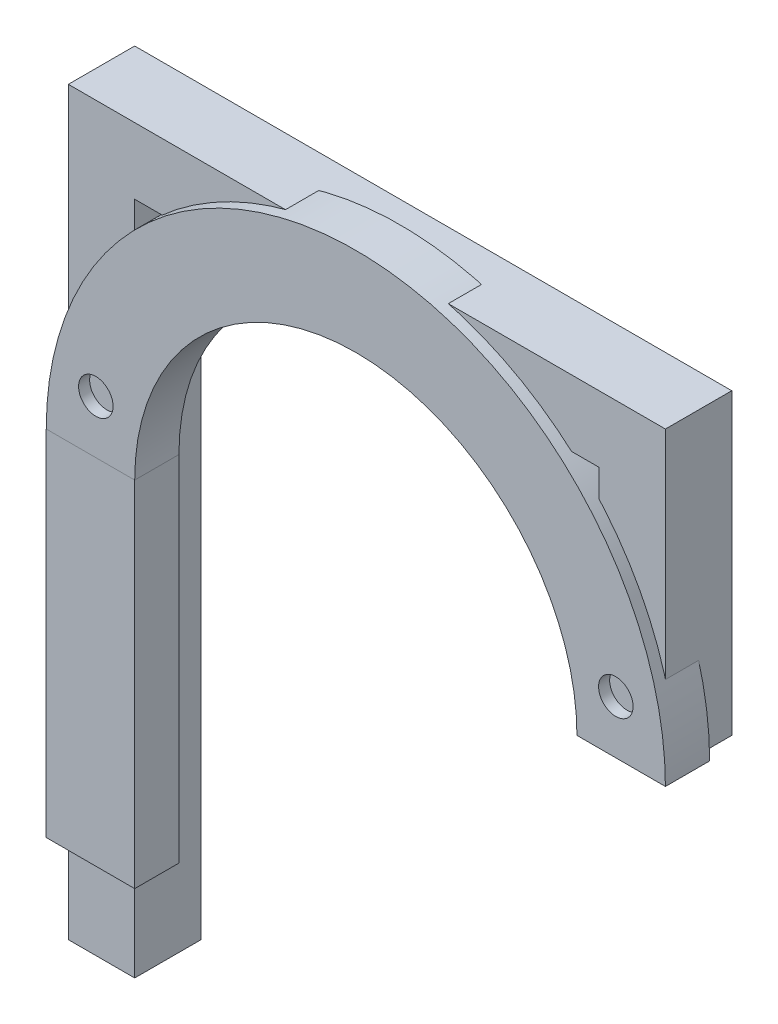
from build123d import *

# Parameters (mm, degrees)
EXTRUDE_THIN3_DEPTH = 4.7625
SKETCH38_W          = 12.7
SKETCH38_H          = 6.35
SKETCH39_R          = 2.4765
CUT_EXTRUDE1_DEPTH  = 7.35
SKETCH42_W          = 12.7
SKETCH42_H          = 6.35
CUT_EXTRUDE2_DEPTH  = 12.7
SKETCH43_W          = 9.525
SKETCH43_H          = 4.7625
BOSS_EXTRUDE4_DEPTH = 12.7
SKETCH45_R          = 2.4765
CUT_EXTRUDE4_DEPTH  = 7.35


with BuildPart() as part:
    # Sketch8 → Extrude-Thin3 (new body, symmetric)
    with BuildSketch(Plane.XY):
        Polygon((4.7625, 0), (4.7625, 96.8375), (71.4375, 96.8375), (71.4375, 63.5), (80.9625, 63.5), (80.9625, 106.3625), (-4.7625, 106.3625), (-4.7625, 0), align=None)
    extrude(amount=EXTRUDE_THIN3_DEPTH, both=True)


with BuildPart() as body_2:
    # Sweep5: sweep along a path in Sketch37
    with BuildLine(Plane.XY) as sweep5_path:
        Line((0, 0), (0, 63.5))
        ThreePointArc((0, 63.5), (38.1, 101.6), (76.2, 63.5))
    # Sketch38 → Sweep5 (sweep)
    with BuildSketch(Plane(origin=(0, 0, 0), x_dir=(1, 0, 0), z_dir=(0, 1, 0))):
        with Locations((0, -3.175)):
            Rectangle(SKETCH38_W, SKETCH38_H)
    sweep(path=sweep5_path.line)

    # Sketch39 → Cut-Extrude1 (cut, through all)
    with BuildSketch(Plane.XY):
        with Locations((75.43022368, 71.12)):
            Circle(SKETCH39_R)
        with Locations((0.76977632, 71.12)):
            Circle(SKETCH39_R)
    extrude(amount=CUT_EXTRUDE1_DEPTH, mode=Mode.SUBTRACT)

    # Sketch42 → Cut-Extrude2 (cut)
    with BuildSketch(Plane.XZ):
        with Locations((0, 3.175)):
            Rectangle(SKETCH42_W, SKETCH42_H)
    extrude(amount=-CUT_EXTRUDE2_DEPTH, mode=Mode.SUBTRACT)

    # Sketch43 → Boss-Extrude4 (add)
    with BuildSketch(Plane.XZ.offset(-12.7)):
        with Locations((0, 2.38125)):
            Rectangle(SKETCH43_W, SKETCH43_H)
    extrude(amount=BOSS_EXTRUDE4_DEPTH)

    # Sketch45 → Cut-Extrude4 (cut, through all)
    with BuildSketch(Plane(origin=(0, 0, 0), x_dir=(-1, 0, 0), z_dir=(0, 0, -1))):
        with Locations((0, 6.35)):
            Circle(SKETCH45_R)
    extrude(amount=-CUT_EXTRUDE4_DEPTH, mode=Mode.SUBTRACT)


solid = Compound([part.part, body_2.part])
